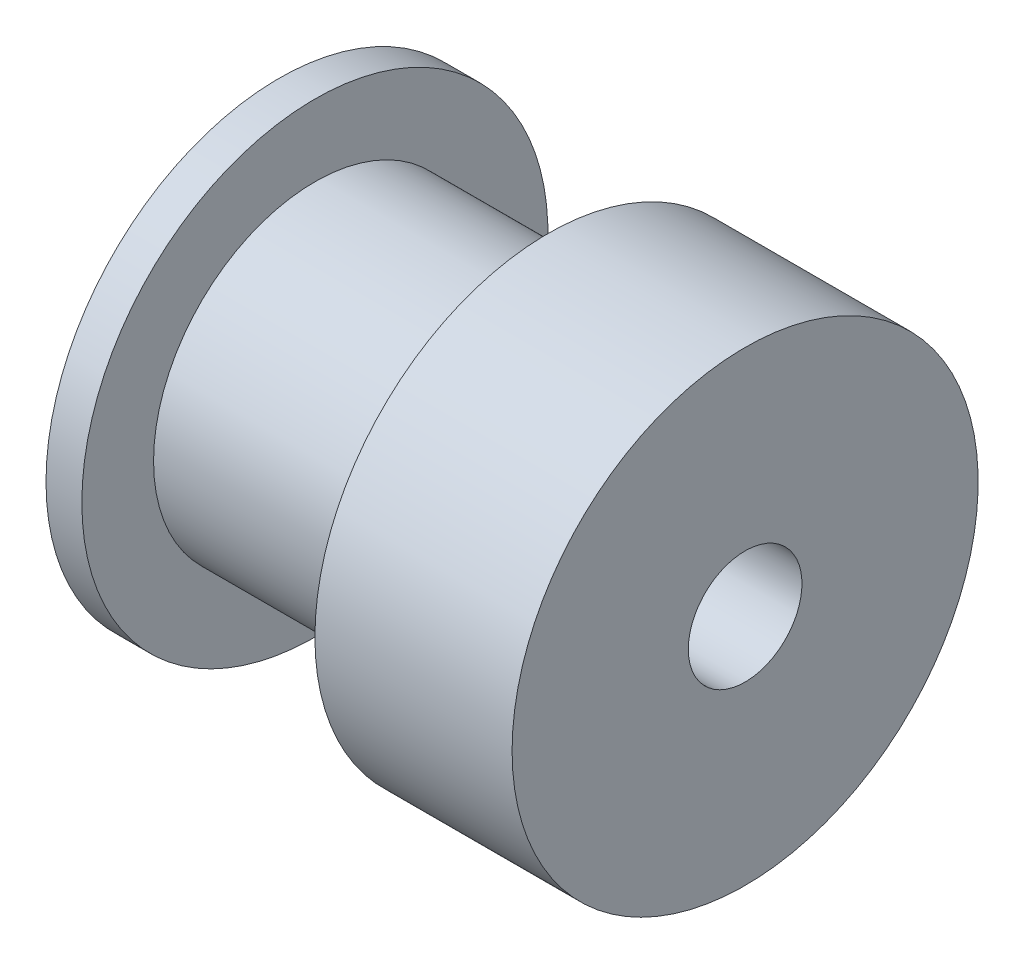
from build123d import *

# Parameters (mm, degrees)
SKETCH_2_R          = 1.585
CUT_EXTRUDE_1_DEPTH = 14


with BuildPart() as part:
    # 草图1 → 旋转1 (revolve)
    with BuildSketch(Plane.XY):
        Polygon((6.5, -3.25), (-6.5, -3.25), (-6.5, 3.25), (-5.5, 3.25), (-5.5, 1.25), (1, 1.25), (1, 3.25), (6.5, 3.25), align=None)
    revolve(axis=Axis((-6.5, -3.25, 0), (1, 0, 0)))

    # 草图2 → 切除-拉伸1 (cut, through all)
    with BuildSketch(Plane.ZY.offset(6.5)):
        with Locations((0, -3.25)):
            Circle(SKETCH_2_R)
    extrude(amount=-CUT_EXTRUDE_1_DEPTH, mode=Mode.SUBTRACT)


solid = part.part
